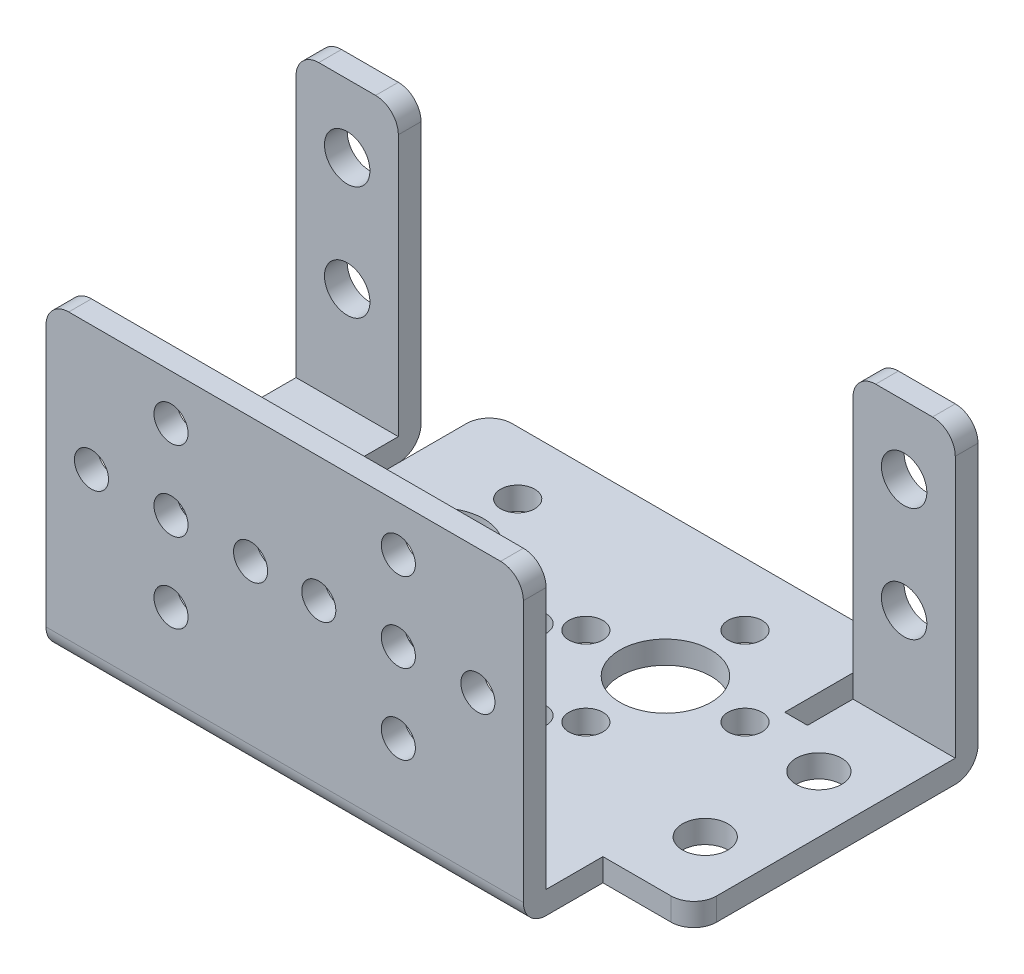
from build123d import *

# Parameters (mm, degrees)
SKETCH1_W           = 42
SKETCH1_H           = 27
SKETCH1_R           = 1.5
BOSS_EXTRUDE1_DEPTH = 2
SKETCH2_R           = 2
SKETCH2_R_2         = 4
SKETCH2_R_3         = 1.5
BOSS_EXTRUDE2_DEPTH = 2
CUT_EXTRUDE1_DEPTH  = 2
FILLET1_R           = 2
FILLET2_R           = 2
FILLET3_R           = 2
FILLET4_R           = 2
FILLET5_R           = 2
BOSS_EXTRUDE3_DEPTH = 2
FILLET6_R           = 2
FILLET7_R           = 2
SKETCH5_R           = 2
CUT_EXTRUDE2_DEPTH  = 2


with BuildPart() as part:
    # Sketch1 → Boss-Extrude1 (new body)
    with BuildSketch(Plane.XY):
        with Locations((21, 13.5)):
            Rectangle(SKETCH1_W, SKETCH1_H)
        with Locations((11, 16)):
            Circle(SKETCH1_R, mode=Mode.SUBTRACT)
        with Locations((11, 23)):
            Circle(SKETCH1_R, mode=Mode.SUBTRACT)
        with Locations((18, 16)):
            Circle(SKETCH1_R, mode=Mode.SUBTRACT)
        with Locations((4, 16)):
            Circle(SKETCH1_R, mode=Mode.SUBTRACT)
        with Locations((11, 9)):
            Circle(SKETCH1_R, mode=Mode.SUBTRACT)
        with Locations((31, 16)):
            Circle(SKETCH1_R, mode=Mode.SUBTRACT)
        with Locations((38, 16)):
            Circle(SKETCH1_R, mode=Mode.SUBTRACT)
        with Locations((31, 23)):
            Circle(SKETCH1_R, mode=Mode.SUBTRACT)
        with Locations((24, 16)):
            Circle(SKETCH1_R, mode=Mode.SUBTRACT)
        with Locations((31, 9)):
            Circle(SKETCH1_R, mode=Mode.SUBTRACT)
    extrude(amount=-BOSS_EXTRUDE1_DEPTH)

    # Sketch2 → Boss-Extrude2 (add)
    with BuildSketch(Plane.XZ):
        with BuildLine():
            Line((0, -32), (0, -36))
            Line((0, -36), (42, -36))
            Line((42, -36), (42, -32))
            Line((42, -32), (50, -32))
            Line((50, -32), (50, -9))
            ThreePointArc((50, -9), (49.414213562, -7.585786438), (48, -7))
            Line((48, -7), (42, -7))
            Line((42, -7), (42, 0))
            Line((42, 0), (0, 0))
            Line((0, 0), (0, -7))
            Line((0, -7), (-6, -7))
            ThreePointArc((-6, -7), (-7.414213562, -7.585786438), (-8, -9))
            Line((-8, -9), (-8, -32))
            Line((-8, -32), (0, -32))
        make_face()
        with Locations((45, -13)):
            Circle(SKETCH2_R, mode=Mode.SUBTRACT)
        with Locations((45, -23)):
            Circle(SKETCH2_R, mode=Mode.SUBTRACT)
        with Locations((-3, -13)):
            Circle(SKETCH2_R, mode=Mode.SUBTRACT)
        with Locations((-3, -23)):
            Circle(SKETCH2_R, mode=Mode.SUBTRACT)
        with Locations((11, -23.5)):
            Circle(SKETCH2_R_2, mode=Mode.SUBTRACT)
        with Locations((31, -23.5)):
            Circle(SKETCH2_R_2, mode=Mode.SUBTRACT)
        with Locations((21, -14.5)):
            Circle(SKETCH2_R_2, mode=Mode.SUBTRACT)
        with Locations((11, -16.5)):
            Circle(SKETCH2_R_3, mode=Mode.SUBTRACT)
        with Locations((11, -30.5)):
            Circle(SKETCH2_R_3, mode=Mode.SUBTRACT)
        with Locations((18, -23.5)):
            Circle(SKETCH2_R_3, mode=Mode.SUBTRACT)
        with Locations((4, -23.5)):
            Circle(SKETCH2_R_3, mode=Mode.SUBTRACT)
        with Locations((31, -30.5)):
            Circle(SKETCH2_R_3, mode=Mode.SUBTRACT)
        with Locations((24, -23.5)):
            Circle(SKETCH2_R_3, mode=Mode.SUBTRACT)
        with Locations((31, -16.5)):
            Circle(SKETCH2_R_3, mode=Mode.SUBTRACT)
        with Locations((38, -23.5)):
            Circle(SKETCH2_R_3, mode=Mode.SUBTRACT)
        with Locations((21, -21.5)):
            Circle(SKETCH2_R_3, mode=Mode.SUBTRACT)
        with Locations((21, -7.5)):
            Circle(SKETCH2_R_3, mode=Mode.SUBTRACT)
        with Locations((28, -14.5)):
            Circle(SKETCH2_R_3, mode=Mode.SUBTRACT)
        with Locations((14, -14.5)):
            Circle(SKETCH2_R_3, mode=Mode.SUBTRACT)
    extrude(amount=-BOSS_EXTRUDE2_DEPTH)

    # Sketch3 → Cut-Extrude1 (cut)
    with BuildSketch(Plane.XZ):
        Polygon((39, -36), (39, -26), (41, -26), (41, -32), (42, -32), (42, -36), align=None)
    cut_extrude1 = extrude(amount=-CUT_EXTRUDE1_DEPTH, mode=Mode.SUBTRACT)

    # Mirror1: Cut-Extrude1 across plane
    add(cut_extrude1.mirror(Plane(origin=(21, 0, 0), x_dir=(0, 0, 1), z_dir=(1, 0, 0))), mode=Mode.SUBTRACT)

    # Fillet1
    fillet1_edges = [part.edges().sort_by_distance(p)[0] for p in [
        (3, 1, -36),
    ]]
    fillet(fillet1_edges, radius=FILLET1_R)

    # Fillet2
    fillet2_edges = [part.edges().sort_by_distance(p)[0] for p in [
        (39, 1, -36),
    ]]
    fillet(fillet2_edges, radius=FILLET2_R)

    # Fillet3
    fillet3_edges = [part.edges().sort_by_distance(p)[0] for p in [
        (21, 0, 0),
    ]]
    fillet(fillet3_edges, radius=FILLET3_R)

    # Fillet4
    fillet4_edges = [part.edges().sort_by_distance(p)[0] for p in [
        (42, 27, -1),
    ]]
    fillet(fillet4_edges, radius=FILLET4_R)

    # Fillet5
    fillet5_edges = [part.edges().sort_by_distance(p)[0] for p in [
        (0, 27, -1),
    ]]
    fillet(fillet5_edges, radius=FILLET5_R)

    # Sketch4 → Boss-Extrude3 (add)
    with BuildSketch(Plane(origin=(0, 0, -32), x_dir=(-1, 0, 0), z_dir=(0, 0, -1))):
        with BuildLine():
            Line((8, 0), (-1, 0))
            Line((-1, 0), (-1, 25))
            ThreePointArc((-1, 25), (-0.414213562, 26.414213562), (1, 27))
            Line((1, 27), (6, 27))
            ThreePointArc((6, 27), (7.414213562, 26.414213562), (8, 25))
            Line((8, 25), (8, 0))
        make_face()
    boss_extrude3 = extrude(amount=-BOSS_EXTRUDE3_DEPTH)

    # Mirror2: Boss-Extrude3 across plane
    add(boss_extrude3.mirror(Plane(origin=(21, 0, 0), x_dir=(0, 0, 1), z_dir=(1, 0, 0))))

    # Fillet6
    fillet6_edges = [part.edges().sort_by_distance(p)[0] for p in [
        (45.5, 0, -32),
    ]]
    fillet(fillet6_edges, radius=FILLET6_R)

    # Fillet7
    fillet7_edges = [part.edges().sort_by_distance(p)[0] for p in [
        (-3.5, 0, -32),
    ]]
    fillet(fillet7_edges, radius=FILLET7_R)

    # Sketch5 → Cut-Extrude2 (cut)
    with BuildSketch(Plane(origin=(0, 0, -32), x_dir=(-1, 0, 0), z_dir=(0, 0, -1))):
        with Locations((3.5, 21)):
            Circle(SKETCH5_R)
        with Locations((3.5, 11)):
            Circle(SKETCH5_R)
    cut_extrude2 = extrude(amount=-CUT_EXTRUDE2_DEPTH, mode=Mode.SUBTRACT)

    # Mirror3: Cut-Extrude2 across plane
    add(cut_extrude2.mirror(Plane(origin=(21, 0, 0), x_dir=(0, 0, 1), z_dir=(1, 0, 0))), mode=Mode.SUBTRACT)


solid = part.part
